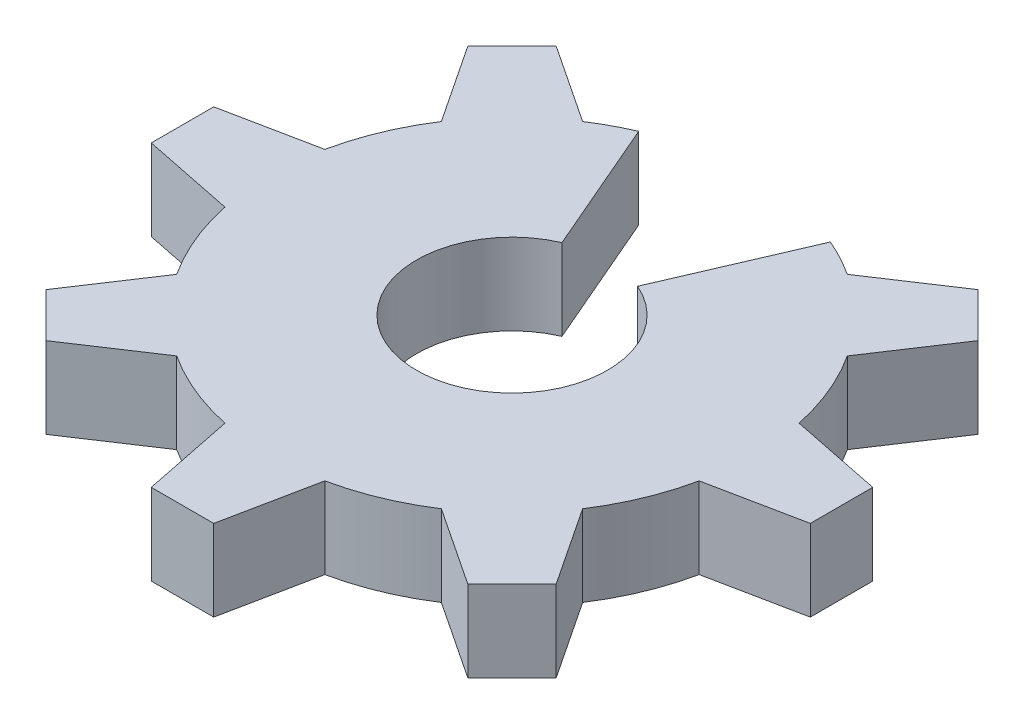
from build123d import *

# Parameters (mm, degrees)
BOSS_EXTRUDE6_DEPTH = 1.3


with BuildPart() as part:
    # Sketch20 → Boss-Extrude6 (new body)
    with BuildSketch(Plane(origin=(0, 0, -30), x_dir=(-1, 0, 0), z_dir=(0, 1, 0))):
        with BuildLine():
            Line((1.53471655, 42.07642804), (0.605184619, 44.234777037))
            ThreePointArc((0.605184619, 44.234777037), (0, 47.17), (-0.605184619, 44.234777037))
            Line((-0.605184619, 44.234777037), (-1.53471655, 42.07642804))
            ThreePointArc((-1.53471655, 42.07642804), (-1.833529499, 42.220560049), (-2.118937454, 42.389691697))
            Line((-2.118937454, 42.389691697), (-3.377398231, 41.555494988))
            Line((-3.377398231, 41.555494988), (-3.730951621, 41.909048379))
            Line((-3.730951621, 41.909048379), (-4.084505012, 42.262601769))
            Line((-4.084505012, 42.262601769), (-3.250308303, 43.521062546))
            ThreePointArc((-3.250308303, 43.521062546), (-3.584652586, 44.155188282), (-3.796630085, 44.84))
            Line((-3.796630085, 44.84), (-5.276362383, 45.14))
            Line((-5.276362383, 45.14), (-5.276362383, 45.64))
            Line((-5.276362383, 45.64), (-5.276362383, 46.14))
            Line((-5.276362383, 46.14), (-3.796630085, 46.44))
            ThreePointArc((-3.796630085, 46.44), (-3.584652586, 47.124811718), (-3.250308303, 47.758937454))
            Line((-3.250308303, 47.758937454), (-4.084505012, 49.017398231))
            Line((-4.084505012, 49.017398231), (-3.730951621, 49.370951621))
            Line((-3.730951621, 49.370951621), (-3.377398231, 49.724505012))
            Line((-3.377398231, 49.724505012), (-2.118937454, 48.890308303))
            ThreePointArc((-2.118937454, 48.890308303), (-1.484811718, 49.224652586), (-0.8, 49.436630085))
            Line((-0.8, 49.436630085), (-0.5, 50.916362383))
            Line((-0.5, 50.916362383), (0, 50.916362383))
            Line((0, 50.916362383), (0.5, 50.916362383))
            Line((0.5, 50.916362383), (0.8, 49.436630085))
            ThreePointArc((0.8, 49.436630085), (1.484811718, 49.224652586), (2.118937454, 48.890308303))
            Line((2.118937454, 48.890308303), (3.377398231, 49.724505012))
            Line((3.377398231, 49.724505012), (3.730951621, 49.370951621))
            Line((3.730951621, 49.370951621), (4.084505012, 49.017398231))
            Line((4.084505012, 49.017398231), (3.250308303, 47.758937454))
            ThreePointArc((3.250308303, 47.758937454), (3.584652586, 47.124811718), (3.796630085, 46.44))
            Line((3.796630085, 46.44), (5.276362383, 46.14))
            Line((5.276362383, 46.14), (5.276362383, 45.64))
            Line((5.276362383, 45.64), (5.276362383, 45.14))
            Line((5.276362383, 45.14), (3.796630085, 44.84))
            ThreePointArc((3.796630085, 44.84), (3.584652586, 44.155188282), (3.250308303, 43.521062546))
            Line((3.250308303, 43.521062546), (4.084505012, 42.262601769))
            Line((4.084505012, 42.262601769), (3.730951621, 41.909048379))
            Line((3.730951621, 41.909048379), (3.377398231, 41.555494988))
            Line((3.377398231, 41.555494988), (2.118937454, 42.389691697))
            ThreePointArc((2.118937454, 42.389691697), (1.833529499, 42.220560049), (1.53471655, 42.07642804))
        make_face()
    extrude(amount=BOSS_EXTRUDE6_DEPTH)


solid = part.part
